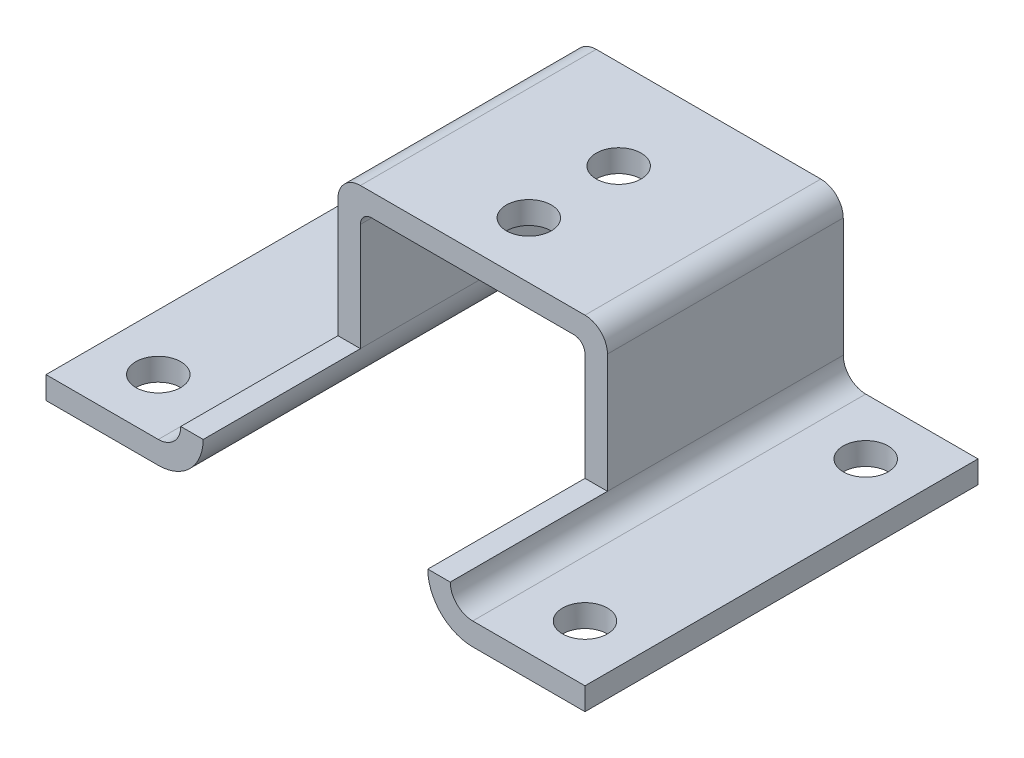
from build123d import *

# Parameters (mm, degrees)
BOSS_EXTRUDE1_DEPTH   = 35
BOSS_EXTRUDE1_2_DEPTH = 35
BOSS_EXTRUDE2_DEPTH   = 21
SKETCH3_R             = 2
CUT_EXTRUDE1_DEPTH    = 46.564112103


with BuildPart() as part:
    # Sketch2 → Boss-Extrude1 (new body)
    with BuildSketch(Plane.XY):
        with BuildLine():
            Line((-24, 18.267872099), (-24, 16.267872099))
            Line((-24, 16.267872099), (-14, 16.267872099))
            ThreePointArc((-14, 16.267872099), (-11.171572875, 17.439444974), (-10, 20.267872099))
            Line((-10, 20.267872099), (-12, 20.267872099))
            ThreePointArc((-12, 20.267872099), (-12.585786438, 18.853658537), (-14, 18.267872099))
            Line((-14, 18.267872099), (-24, 18.267872099))
        make_face()
    extrude(amount=BOSS_EXTRUDE1_DEPTH)



with BuildPart() as body_2:
    # Sketch2 → Boss-Extrude1 2 (new body)
    with BuildSketch(Plane.XY):
        with BuildLine():
            Line((12, 20.267872099), (10, 20.267872099))
            ThreePointArc((10, 20.267872099), (11.171572875, 17.439444974), (14, 16.267872099))
            Line((14, 16.267872099), (24, 16.267872099))
            Line((24, 16.267872099), (24, 18.267872099))
            Line((24, 18.267872099), (14, 18.267872099))
            ThreePointArc((14, 18.267872099), (12.585786438, 18.853658537), (12, 20.267872099))
        make_face()
    extrude(amount=BOSS_EXTRUDE1_2_DEPTH)


with BuildPart() as part_1:
    add(part.part)

    add(body_2.part)  # Boss-Extrude2 merges body 2
    # Sketch2_3 → Boss-Extrude2 (add)
    with BuildSketch(Plane.XY):
        with BuildLine():
            Line((-12, 20.267872099), (-10, 20.267872099))
            Line((-10, 20.267872099), (-10, 29.853658537))
            ThreePointArc((-10, 29.853658537), (-9.707106781, 30.560765318), (-9, 30.853658537))
            Line((-9, 30.853658537), (9, 30.853658537))
            ThreePointArc((9, 30.853658537), (9.707106781, 30.560765318), (10, 29.853658537))
            Line((10, 29.853658537), (10, 20.267872099))
            Line((10, 20.267872099), (12, 20.267872099))
            Line((12, 20.267872099), (12, 30.853658537))
            ThreePointArc((12, 30.853658537), (11.414213562, 32.267872099), (10, 32.853658537))
            Line((10, 32.853658537), (-10, 32.853658537))
            ThreePointArc((-10, 32.853658537), (-11.414213562, 32.267872099), (-12, 30.853658537))
            Line((-12, 30.853658537), (-12, 20.267872099))
        make_face()
    extrude(amount=BOSS_EXTRUDE2_DEPTH)

    # Sketch3 → Cut-Extrude1 (cut, through all)
    with BuildSketch(Plane(origin=(0, 32.853658537, 0), x_dir=(1, 0, 0), z_dir=(0, 1, 0))):
        with Locations((0, -8)):
            Circle(SKETCH3_R)
        with Locations((0, -16)):
            Circle(SKETCH3_R)
        with Locations((-19, -5)):
            Circle(SKETCH3_R)
        with Locations((-19, -30)):
            Circle(SKETCH3_R)
        with Locations((19, -5)):
            Circle(SKETCH3_R)
        with Locations((19, -30)):
            Circle(SKETCH3_R)
    extrude(amount=-CUT_EXTRUDE1_DEPTH, mode=Mode.SUBTRACT)


solid = part_1.part
